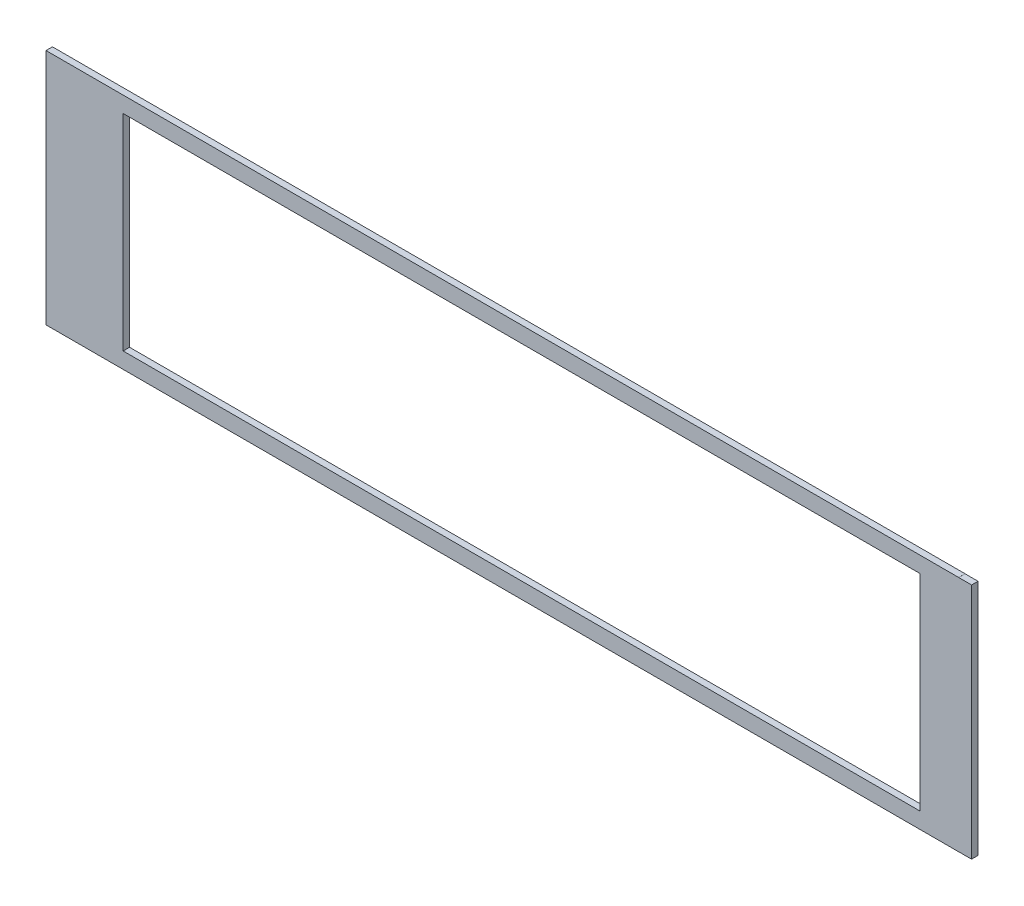
from build123d import *

# Parameters (mm, degrees)
BOSS_EXTRUDE1_DEPTH = 3.175


with BuildPart() as part:
    # Sketch1 → Boss-Extrude1 (new body)
    with BuildSketch(Plane.XY):
        Polygon((38.1, 58.683525), (0, 58.683525), (0, 0), (450.85, 0), (450.85, 0.0254), (457.2, 0.0254), (457.2, 58.683525), (431.8, 58.683525), (431.8, 7.883525), (38.1, 7.883525), align=None)
        Polygon((0, 117.36705), (0, 58.683525), (38.1, 58.683525), (38.1, 109.483525), (431.8, 109.483525), (431.8, 58.683525), (457.2, 58.683525), (457.2, 117.34165), (450.85, 117.34165), (450.85, 117.36705), align=None)
    extrude(amount=BOSS_EXTRUDE1_DEPTH)


solid = part.part
